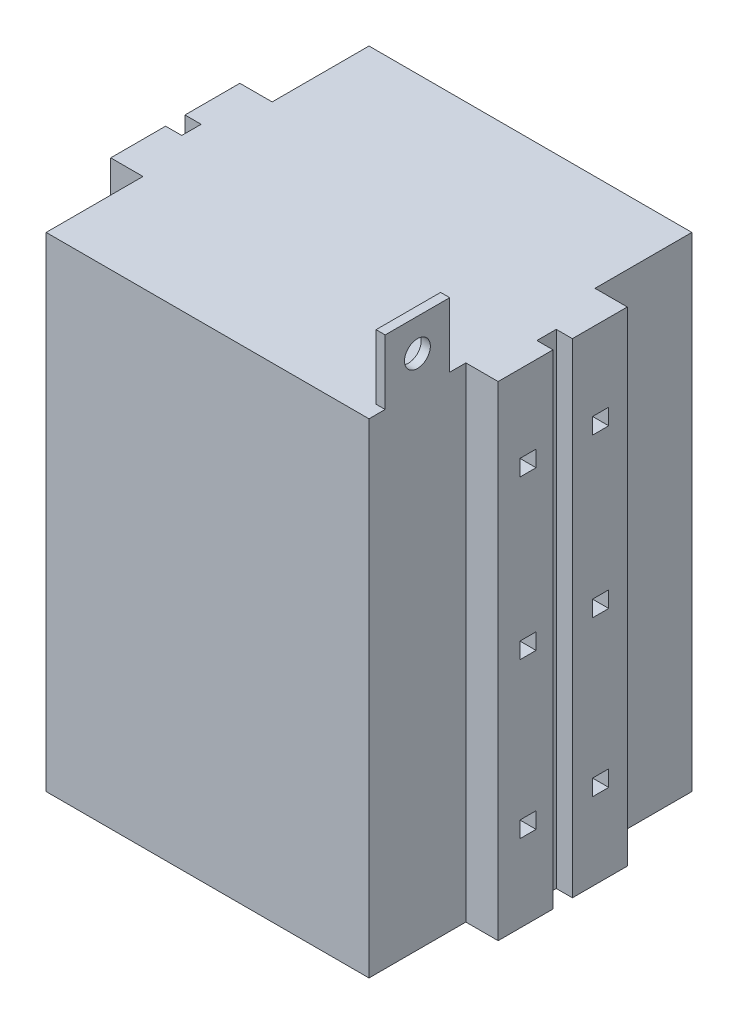
from build123d import *

# Parameters (mm, degrees)
ESQUISSE1_W             = 100
ESQUISSE1_H             = 150
BOSS_EXTRU_1_DEPTH      = 100
ESQUISSE2_W             = 90
ESQUISSE2_H             = 140
ENL_V_MAT_EXTRU_1_DEPTH = 95
ESQUISSE4_W             = 40
ESQUISSE4_H             = 150
BOSS_EXTRU_2_DEPTH      = 10
ESQUISSE5_W             = 6
ESQUISSE5_H             = 150
ENL_V_MAT_EXTRU_2_DEPTH = 5
ESQUISSE7_W             = 40
ESQUISSE7_H             = 150
BOSS_EXTRU_3_DEPTH      = 10
ESQUISSE8_W             = 6
ESQUISSE8_H             = 150
ENL_V_MAT_EXTRU_3_DEPTH = 5
ESQUISSE9_W             = 5
ESQUISSE9_H             = 5
ENL_V_MAT_EXTRU_4_DEPTH = 121
ESQUISSE10_W            = 2.816855809
ESQUISSE10_H            = 20
BOSS_EXTRU_4_DEPTH      = 20
ESQUISSE11_R            = 4
ENL_V_MAT_EXTRU_5_DEPTH = 111


with BuildPart() as part:
    # Esquisse1 → Boss.-Extru.1 (new body)
    with BuildSketch(Plane.XY):
        with Locations((50, 75)):
            Rectangle(ESQUISSE1_W, ESQUISSE1_H)
    extrude(amount=BOSS_EXTRU_1_DEPTH)

    # Esquisse2 → Enlèv. mat.-Extru.1 (cut)
    with BuildSketch(Plane(origin=(0, 0, 0), x_dir=(-1, 0, 0), z_dir=(0, 0, -1))):
        with Locations((-50, 75)):
            Rectangle(ESQUISSE2_W, ESQUISSE2_H)
    extrude(amount=-ENL_V_MAT_EXTRU_1_DEPTH, mode=Mode.SUBTRACT)

    # Esquisse4 → Boss.-Extru.2 (add)
    with BuildSketch(Plane.ZY):
        with Locations((50, 75)):
            Rectangle(ESQUISSE4_W, ESQUISSE4_H)
    extrude(amount=BOSS_EXTRU_2_DEPTH)

    # Esquisse5 → Enlèv. mat.-Extru.2 (cut)
    with BuildSketch(Plane.ZY.offset(10)):
        with Locations((50, 75)):
            Rectangle(ESQUISSE5_W, ESQUISSE5_H)
    extrude(amount=-ENL_V_MAT_EXTRU_2_DEPTH, mode=Mode.SUBTRACT)

    # Esquisse7 → Boss.-Extru.3 (add)
    with BuildSketch(Plane(origin=(100, 0, 0), x_dir=(0, 0, -1), z_dir=(1, 0, 0))):
        with Locations((-50, 75)):
            Rectangle(ESQUISSE7_W, ESQUISSE7_H)
    extrude(amount=BOSS_EXTRU_3_DEPTH)

    # Esquisse8 → Enlèv. mat.-Extru.3 (cut)
    with BuildSketch(Plane(origin=(110, 0, 0), x_dir=(0, 0, -1), z_dir=(1, 0, 0))):
        with Locations((-50, 75)):
            Rectangle(ESQUISSE8_W, ESQUISSE8_H)
    extrude(amount=-ENL_V_MAT_EXTRU_3_DEPTH, mode=Mode.SUBTRACT)

    # Esquisse9 → Enlèv. mat.-Extru.4 (cut, through all)
    with BuildSketch(Plane(origin=(110, 0, 0), x_dir=(0, 0, -1), z_dir=(1, 0, 0))):
        with Locations((-38.25, 123.5)):
            Rectangle(ESQUISSE9_W, ESQUISSE9_H)
        with Locations((-60.75, 74.5)):
            Rectangle(ESQUISSE9_W, ESQUISSE9_H)
        with Locations((-38.25, 74.5)):
            Rectangle(ESQUISSE9_W, ESQUISSE9_H)
        with Locations((-60.75, 26.5)):
            Rectangle(ESQUISSE9_W, ESQUISSE9_H)
        with Locations((-60.75, 123.5)):
            Rectangle(ESQUISSE9_W, ESQUISSE9_H)
        with Locations((-38.25, 26.5)):
            Rectangle(ESQUISSE9_W, ESQUISSE9_H)
    extrude(amount=-ENL_V_MAT_EXTRU_4_DEPTH, mode=Mode.SUBTRACT)

    # Esquisse10 → Boss.-Extru.4 (add)
    with BuildSketch(Plane(origin=(0, 150, 0), x_dir=(1, 0, 0), z_dir=(0, 1, 0))):
        with Locations((98.591572095, -85)):
            Rectangle(ESQUISSE10_W, ESQUISSE10_H)
    extrude(amount=BOSS_EXTRU_4_DEPTH)

    # Esquisse11 → Enlèv. mat.-Extru.5 (cut, through all)
    with BuildSketch(Plane(origin=(100, 0, 0), x_dir=(0, 0, -1), z_dir=(1, 0, 0))):
        with Locations((-85, 160)):
            Circle(ESQUISSE11_R)
    extrude(amount=-ENL_V_MAT_EXTRU_5_DEPTH, mode=Mode.SUBTRACT)


solid = part.part
